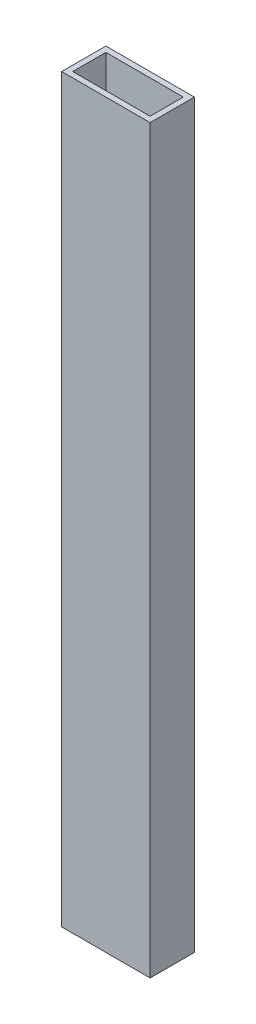
from build123d import *

# Parameters (mm, degrees)
SKETCH1_W           = 50.8
SKETCH1_H           = 25.4
SKETCH1_W_2         = 44.45
SKETCH1_H_2         = 19.05
BOSS_EXTRUDE1_DEPTH = 425.45


with BuildPart() as part:
    # Sketch1 → Boss-Extrude1 (new body)
    with BuildSketch(Plane(origin=(0, 0, 0), x_dir=(1, 0, 0), z_dir=(0, 1, 0))):
        with Locations((25.4, 12.7)):
            Rectangle(SKETCH1_W, SKETCH1_H)
        with Locations((25.4, 12.7)):
            Rectangle(SKETCH1_W_2, SKETCH1_H_2, mode=Mode.SUBTRACT)
    extrude(amount=BOSS_EXTRUDE1_DEPTH)


solid = part.part
